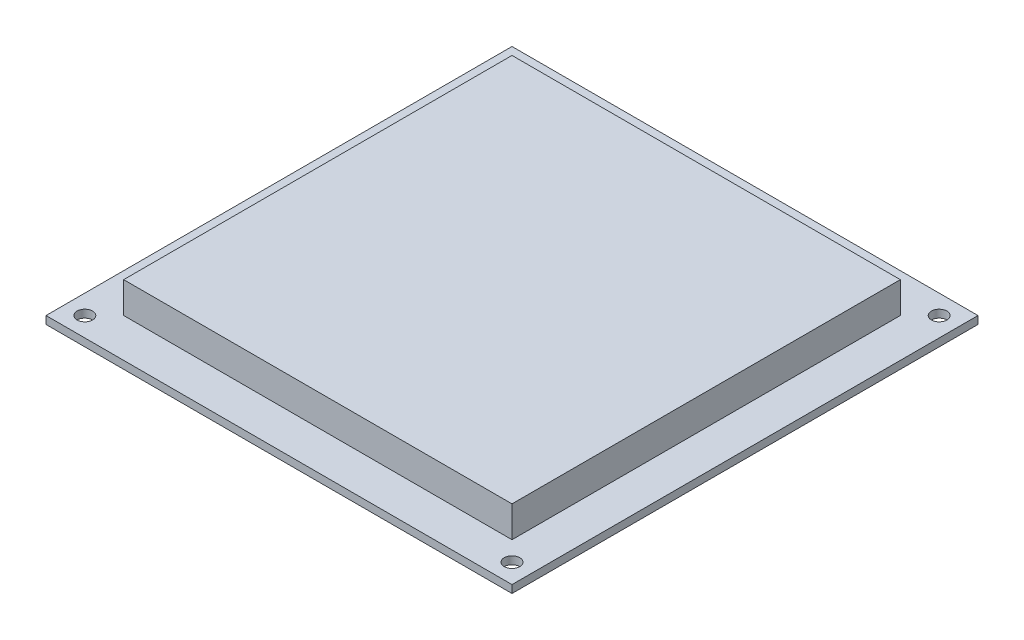
from build123d import *

# Parameters (mm, degrees)
SKETCH1_W           = 152.4
SKETCH1_H           = 152.4
BOSS_EXTRUDE1_DEPTH = 2.54
SKETCH9_R           = 2.54
CUT_EXTRUDE5_DEPTH  = 3.54
SKETCH10_W          = 127
SKETCH10_H          = 127
BOSS_EXTRUDE2_DEPTH = 10.16


with BuildPart() as part:
    # Sketch1 → Boss-Extrude1 (new body)
    with BuildSketch(Plane(origin=(0, 0, 0), x_dir=(1, 0, 0), z_dir=(0, 1, 0))):
        Rectangle(SKETCH1_W, SKETCH1_H)
    extrude(amount=-BOSS_EXTRUDE1_DEPTH)

    # Sketch9 → Cut-Extrude5 (cut, through all)
    with BuildSketch(Plane(origin=(0, 0, 0), x_dir=(1, 0, 0), z_dir=(0, 1, 0))):
        with Locations((-69.85, -69.85)):
            Circle(SKETCH9_R)
        with Locations((69.85, -69.85)):
            Circle(SKETCH9_R)
        with Locations((69.85, 69.85)):
            Circle(SKETCH9_R)
        with Locations((-69.85, 69.85)):
            Circle(SKETCH9_R)
    extrude(amount=-CUT_EXTRUDE5_DEPTH, mode=Mode.SUBTRACT)

    # Sketch10 → Boss-Extrude2 (add)
    with BuildSketch(Plane(origin=(0, 0, 0), x_dir=(1, 0, 0), z_dir=(0, 1, 0))):
        Rectangle(SKETCH10_W, SKETCH10_H)
    extrude(amount=BOSS_EXTRUDE2_DEPTH)


solid = part.part
